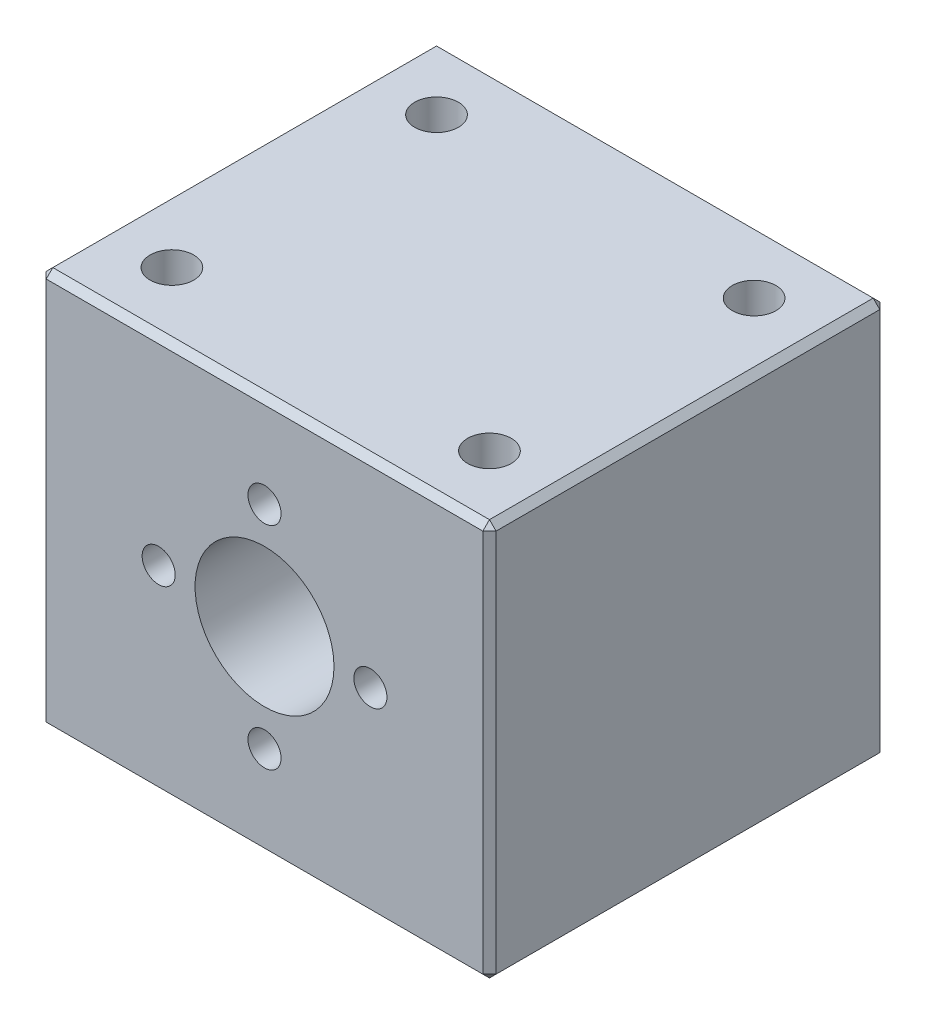
from build123d import *

# Parameters (mm, degrees)
SKETCH_1_W          = 34
SKETCH_1_H          = 30
EXTRUDE_1_DEPTH     = 15
SKETCH_3_R          = 5.25
CUT_EXTRUDE_1_DEPTH = 31
M3X0_5_1_D          = 2.5
M3X0_5_1_DEPTH      = 10
M3X0_5_1_TIP        = 0.751075774
M4X0_7_1_D          = 3.3
M4X0_7_1_DEPTH      = 20
M4X0_7_1_TIP        = 0.991420021
CHAMFER1_SIZE       = 0.5


with BuildPart() as part:
    # 草圖1 → 填料-伸長1 (new body, symmetric)
    with BuildSketch(Plane.XY):
        Rectangle(SKETCH_1_W, SKETCH_1_H)
    extrude(amount=EXTRUDE_1_DEPTH, both=True)

    # 草圖3 → 除料-伸長1 (cut, through all)
    with BuildSketch(Plane.XY.offset(15)):
        Circle(SKETCH_3_R)
    extrude(amount=-CUT_EXTRUDE_1_DEPTH, mode=Mode.SUBTRACT)

    # M3x0.5 螺紋孔1
    with Locations(Plane.XY.offset(15)):
        with Locations((8, 0), (-8, 0), (0, 8), (0, -8)):
            Hole(M3X0_5_1_D / 2, depth=M3X0_5_1_DEPTH)
            with Locations((0, 0, -(M3X0_5_1_DEPTH + M3X0_5_1_TIP / 2))):  # 118° drill point
                Cone(0, M3X0_5_1_D / 2, M3X0_5_1_TIP, mode=Mode.SUBTRACT)

    # M4x0.7 螺紋孔1
    with Locations(Plane(origin=(0, 15, 0), x_dir=(1, 0, 0), z_dir=(0, 1, 0))):
        with Locations((12, -10), (-12, 10), (-12, -10), (12, 10)):
            Hole(M4X0_7_1_D / 2, depth=M4X0_7_1_DEPTH)
            with Locations((0, 0, -(M4X0_7_1_DEPTH + M4X0_7_1_TIP / 2))):  # 118° drill point
                Cone(0, M4X0_7_1_D / 2, M4X0_7_1_TIP, mode=Mode.SUBTRACT)

    # Chamfer1
    chamfer1_edges = [part.edges().sort_by_distance(p)[0] for p in [
        (-17, 0, 15),
        (0, -15, 15),
        (17, 0, 15),
        (0, -15, -15),
        (-17, 0, -15),
        (0, 15, -15),
        (17, 0, -15),
        (0, 15, 15),
        (17, -15, 0),
        (-17, -15, 0),
        (-17, 15, 0),
        (17, 15, 0),
    ]]
    chamfer(chamfer1_edges, length=CHAMFER1_SIZE)


solid = part.part
